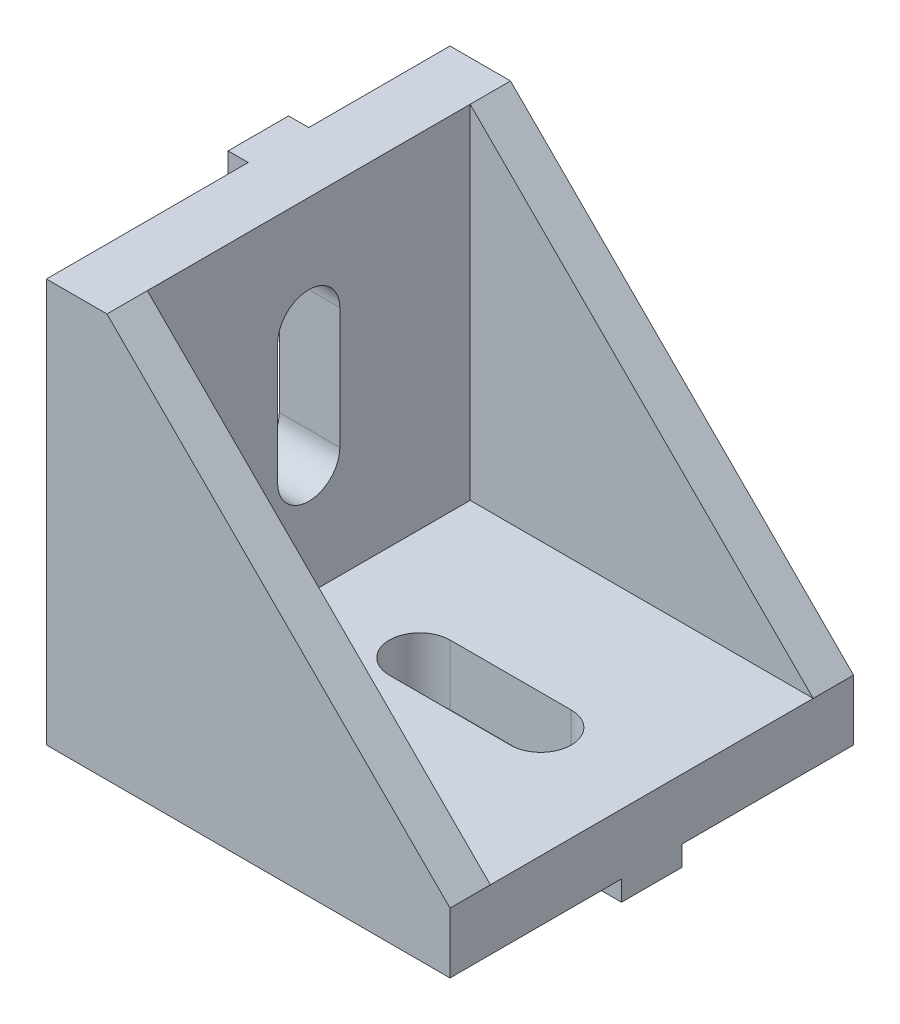
from build123d import *

# Parameters (mm, degrees)
SALIENTE_EXTRUIR1_DEPTH = 20
SALIENTE_EXTRUIR2_DEPTH = 2
SALIENTE_EXTRUIR3_DEPTH = 2
CORTAR_EXTRUIR1_DEPTH   = 4
CORTAR_EXTRUIR2_DEPTH   = 4
CROQUIS6_W              = 1.5
CROQUIS6_H              = 3
SALIENTE_EXTRUIR4_DEPTH = 1
CROQUIS7_W              = 3
CROQUIS7_H              = 1.5
CROQUIS7_W_2            = 1.5
SALIENTE_EXTRUIR6_DEPTH = 1


with BuildPart() as part:
    # Croquis1 → Saliente-Extruir1 (new body)
    with BuildSketch(Plane.XY):
        Polygon((0, 20), (3, 20), (3, 3), (20, 3), (20, 0), (0, 0), align=None)
    extrude(amount=SALIENTE_EXTRUIR1_DEPTH)

    # Croquis2 → Saliente-Extruir2 (add)
    with BuildSketch(Plane.XY.offset(20)):
        Polygon((3, 20), (20, 3), (20, 0), (0, 0), (0, 20), align=None)
    extrude(amount=-SALIENTE_EXTRUIR2_DEPTH)

    # Croquis3 → Saliente-Extruir3 (add)
    with BuildSketch(Plane(origin=(0, 0, 0), x_dir=(-1, 0, 0), z_dir=(0, 0, -1))):
        Polygon((0, 20), (-3, 20), (-20, 3), (-20, 0), (0, 0), align=None)
    extrude(amount=-SALIENTE_EXTRUIR3_DEPTH)

    # Croquis4 → Cortar-Extruir1 (cut, through all)
    with BuildSketch(Plane(origin=(3, 0, 0), x_dir=(0, 0, -1), z_dir=(1, 0, 0))):
        with BuildLine():
            Line((-11.54072, 8.5), (-11.54072, 14.5))
            ThreePointArc((-11.54072, 14.5), (-10, 16.04072), (-8.45928, 14.5))
            Line((-8.45928, 14.5), (-8.45928, 8.5))
            ThreePointArc((-8.45928, 8.5), (-10, 6.95928), (-11.54072, 8.5))
        make_face()
    extrude(amount=-CORTAR_EXTRUIR1_DEPTH, mode=Mode.SUBTRACT)

    # Croquis5 → Cortar-Extruir2 (cut, through all)
    with BuildSketch(Plane(origin=(0, 3, 0), x_dir=(1, 0, 0), z_dir=(0, 1, 0))):
        with BuildLine():
            Line((8.5, -8.492105493), (14.5, -8.492105493))
            ThreePointArc((14.5, -8.492105493), (16.007894507, -10), (14.5, -11.507894507))
            Line((14.5, -11.507894507), (8.5, -11.507894507))
            ThreePointArc((8.5, -11.507894507), (6.992105493, -10), (8.5, -8.492105493))
        make_face()
    extrude(amount=-CORTAR_EXTRUIR2_DEPTH, mode=Mode.SUBTRACT)

    # Croquis6 → Saliente-Extruir4 (add)
    with BuildSketch(Plane.XZ):
        with Locations((0.75, 10)):
            Rectangle(CROQUIS6_W, CROQUIS6_H)
        with Locations((19.25, 10)):
            Rectangle(CROQUIS6_W, CROQUIS6_H)
    extrude(amount=SALIENTE_EXTRUIR4_DEPTH)

    # Croquis7 → Saliente-Extruir6 (add)
    with BuildSketch(Plane.ZY):
        with Locations((8.5, 19.25)):
            Rectangle(CROQUIS7_W, CROQUIS7_H)
        with Locations((9.25, 0.75)):
            Rectangle(CROQUIS7_W_2, CROQUIS7_H)
    extrude(amount=SALIENTE_EXTRUIR6_DEPTH)


solid = part.part
